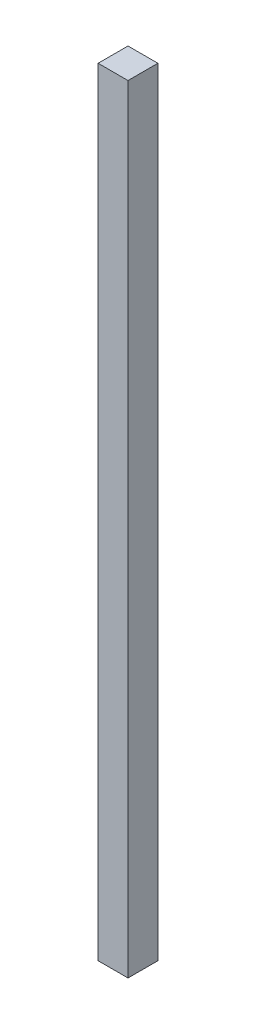
from build123d import *

# Parameters (mm, degrees)
ESQUISSE1_W        = 10
ESQUISSE1_H        = 260
BOSS_EXTRU_1_DEPTH = 10


with BuildPart() as part:
    # Esquisse1 → Boss.-Extru.1 (new body)
    with BuildSketch(Plane.XY):
        with Locations((-16.986659357, -116.472222222)):
            Rectangle(ESQUISSE1_W, ESQUISSE1_H)
    extrude(amount=BOSS_EXTRU_1_DEPTH)


solid = part.part
